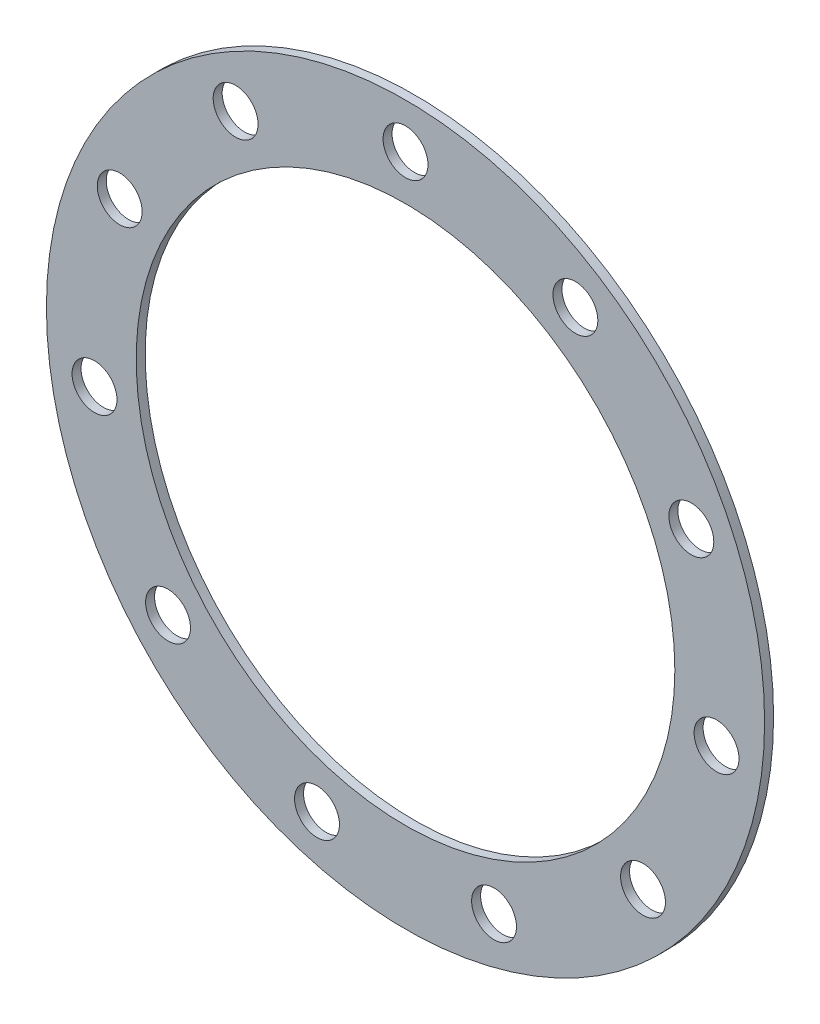
from build123d import *

# Parameters (mm, degrees)
SKETCH1_R           = 40
SKETCH1_R_2         = 30
SKETCH1_R_3         = 2.5
BOSS_EXTRUDE1_DEPTH = 1


with BuildPart() as part:
    # Sketch1 → Boss-Extrude1 (new body)
    with BuildSketch(Plane.XY):
        Circle(SKETCH1_R)
        Circle(SKETCH1_R_2, mode=Mode.SUBTRACT)
        with Locations((0, 35)):
            Circle(SKETCH1_R_3, mode=Mode.SUBTRACT)
        with Locations((18.922428611, 29.443873649)):
            Circle(SKETCH1_R_3, mode=Mode.SUBTRACT)
        with Locations((31.837119837, 14.539525455)):
            Circle(SKETCH1_R_3, mode=Mode.SUBTRACT)
        with Locations((34.643750466, -4.98101934)):
            Circle(SKETCH1_R_3, mode=Mode.SUBTRACT)
        with Locations((26.451235102, -22.920125688)):
            Circle(SKETCH1_R_3, mode=Mode.SUBTRACT)
        with Locations((9.860639489, -33.582254077)):
            Circle(SKETCH1_R_3, mode=Mode.SUBTRACT)
        with Locations((-9.860639489, -33.582254077)):
            Circle(SKETCH1_R_3, mode=Mode.SUBTRACT)
        with Locations((-26.451235102, -22.920125688)):
            Circle(SKETCH1_R_3, mode=Mode.SUBTRACT)
        with Locations((-34.643750466, -4.98101934)):
            Circle(SKETCH1_R_3, mode=Mode.SUBTRACT)
        with Locations((-31.837119837, 14.539525455)):
            Circle(SKETCH1_R_3, mode=Mode.SUBTRACT)
        with Locations((-18.922428611, 29.443873649)):
            Circle(SKETCH1_R_3, mode=Mode.SUBTRACT)
    extrude(amount=BOSS_EXTRUDE1_DEPTH)


solid = part.part
